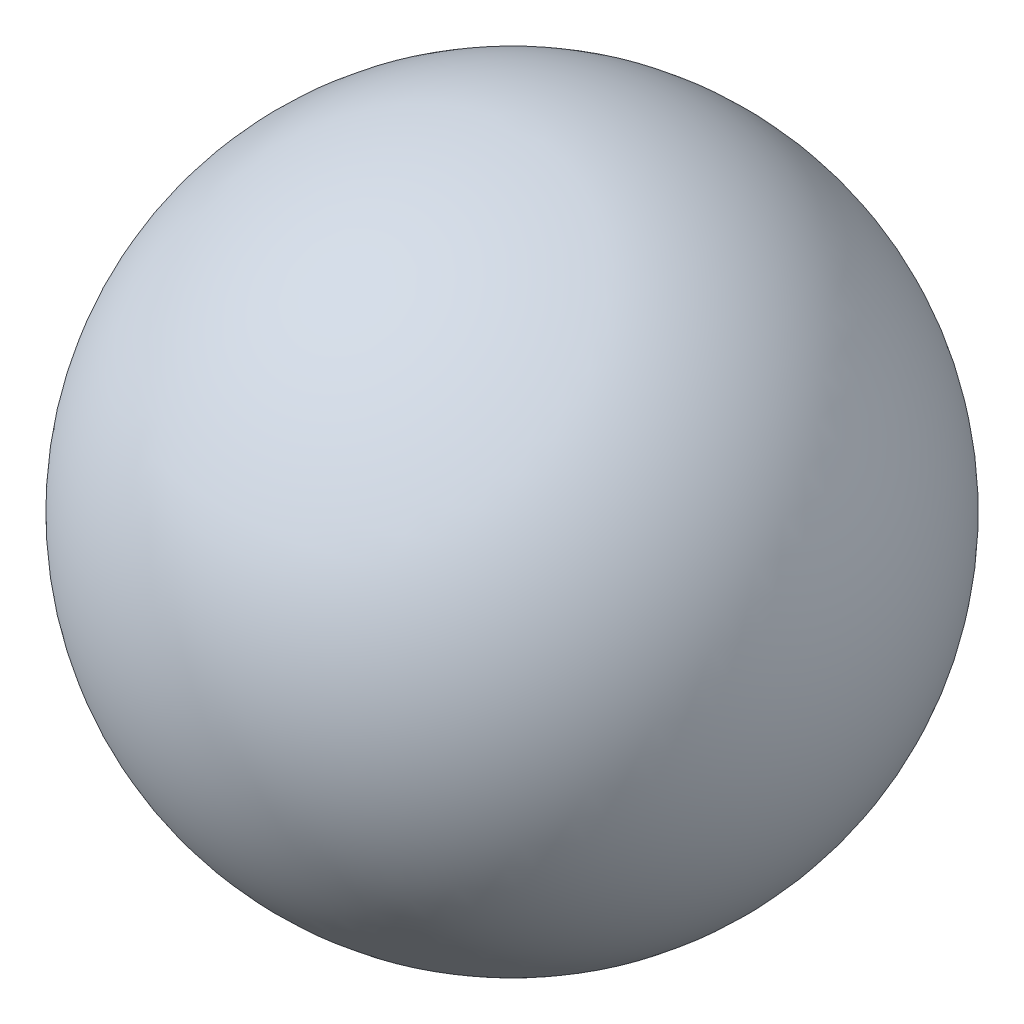
from build123d import *


with BuildPart() as part:
    # Sketch1 → Revolve1 (revolve)
    with BuildSketch(Plane.XY):
        with BuildLine():
            Line((0, 120.65), (0, -120.65))
            ThreePointArc((0, -120.65), (-120.65, 0), (0, 120.65))
        make_face()
    revolve(axis=Axis((0, 120.65, 0), (0, -1, 0)))


solid = part.part
